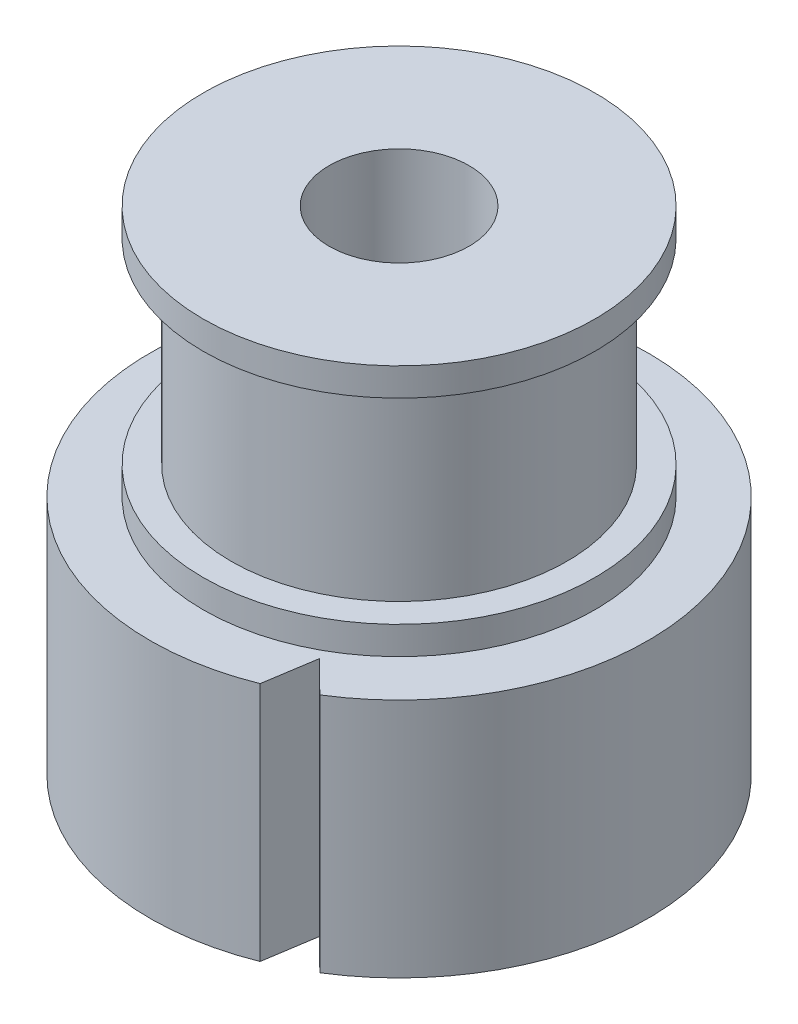
from build123d import *

# Parameters (mm, degrees)
CROQUIS1_R              = 8.9
CROQUIS1_R_2            = 2.5
SALIENTE_EXTRUIR1_DEPTH = 8.6
CROQUIS2_R              = 7
CROQUIS2_R_2            = 2.5
SALIENTE_EXTRUIR2_DEPTH = 1
CROQUIS3_R              = 6
CROQUIS3_R_2            = 2.5
SALIENTE_EXTRUIR3_DEPTH = 7
CROQUIS4_R              = 7
CROQUIS4_R_2            = 2.5
SALIENTE_EXTRUIR4_DEPTH = 1
CORTAR_EXTRUIR1_DEPTH   = 9.6


with BuildPart() as part:
    # Croquis1 → Saliente-Extruir1 (new body)
    with BuildSketch(Plane(origin=(0, 0, 0), x_dir=(1, 0, 0), z_dir=(0, 1, 0))):
        Circle(CROQUIS1_R)
        Circle(CROQUIS1_R_2, mode=Mode.SUBTRACT)
    extrude(amount=SALIENTE_EXTRUIR1_DEPTH)

    # Croquis2 → Saliente-Extruir2 (add)
    with BuildSketch(Plane(origin=(0, 8.6, 0), x_dir=(1, 0, 0), z_dir=(0, 1, 0))):
        Circle(CROQUIS2_R)
        Circle(CROQUIS2_R_2, mode=Mode.SUBTRACT)
    extrude(amount=SALIENTE_EXTRUIR2_DEPTH)

    # Croquis3 → Saliente-Extruir3 (add)
    with BuildSketch(Plane(origin=(0, 9.6, 0), x_dir=(1, 0, 0), z_dir=(0, 1, 0))):
        Circle(CROQUIS3_R)
        Circle(CROQUIS3_R_2, mode=Mode.SUBTRACT)
    extrude(amount=SALIENTE_EXTRUIR3_DEPTH)

    # Croquis4 → Saliente-Extruir4 (add)
    with BuildSketch(Plane(origin=(0, 16.6, 0), x_dir=(1, 0, 0), z_dir=(0, 1, 0))):
        Circle(CROQUIS4_R)
        Circle(CROQUIS4_R_2, mode=Mode.SUBTRACT)
    extrude(amount=SALIENTE_EXTRUIR4_DEPTH)

    # Croquis7 → Cortar-Extruir1 (cut, through all)
    with BuildSketch(Plane(origin=(0, 8.6, 0), x_dir=(1, 0, 0), z_dir=(0, 1, 0))):
        with BuildLine():
            Line((3.299612335, -8.265746091), (3.585413018, -6.433391848))
            Line((3.585413018, -6.433391848), (4.715491895, -7.548121368))
            ThreePointArc((4.715491895, -7.548121368), (4.023583013, -7.938562826), (3.299612335, -8.265746091))
        make_face()
    extrude(amount=-CORTAR_EXTRUIR1_DEPTH, mode=Mode.SUBTRACT)


solid = part.part
